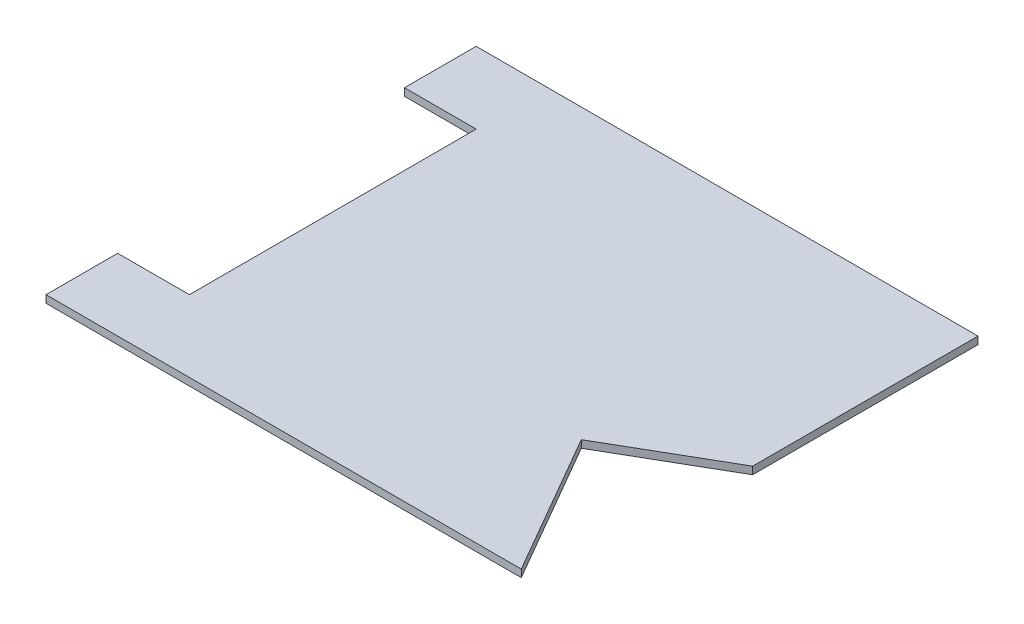
from build123d import *

# Parameters (mm, degrees)
BOSS_EXTRUDE1_DEPTH = 15.875


with BuildPart() as part:
    # Sketch1 → Boss-Extrude1 (new body)
    with BuildSketch(Plane(origin=(0, 0, 0), x_dir=(1, 0, 0), z_dir=(0, 1, 0))):
        Polygon((0, -762), (152.4, -762), (152.4, -152.4), (0, -152.4), (0, 0), (1066.8, 0), (1066.8, -479.0186), (835.8886, -612.3432), (1010.285, -914.4), (0, -914.4), align=None)
    extrude(amount=BOSS_EXTRUDE1_DEPTH)


solid = part.part
